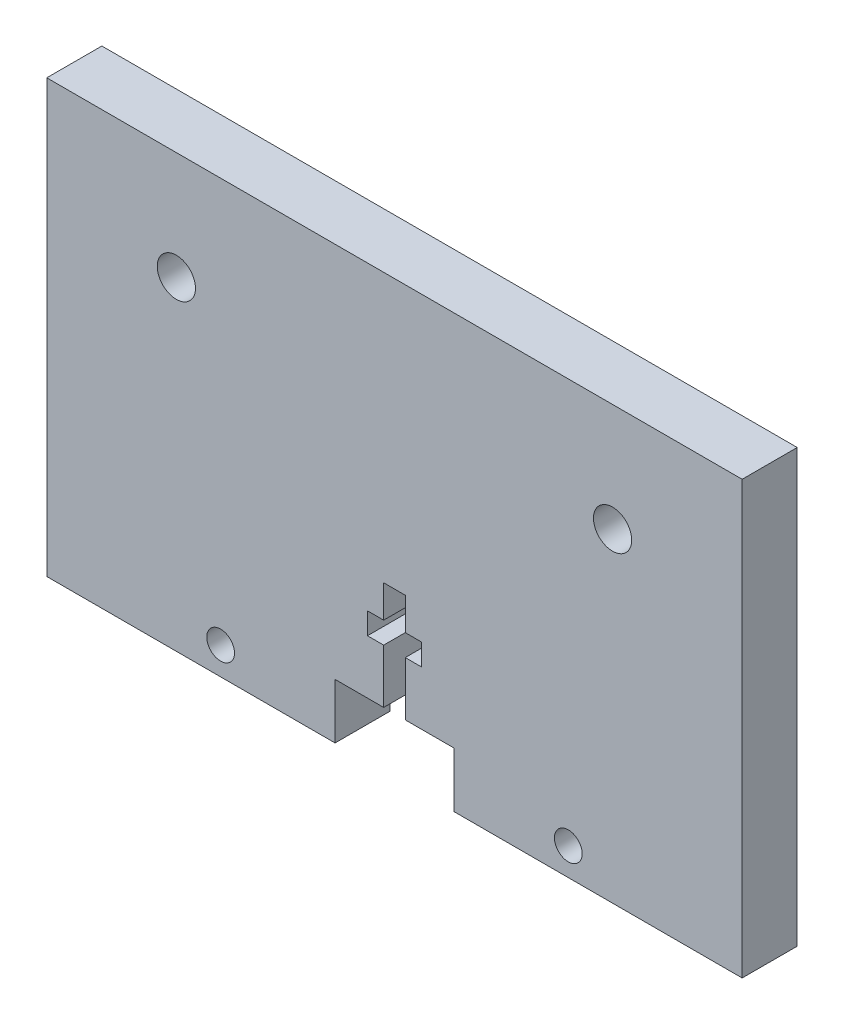
from build123d import *

# Parameters (mm, degrees)
SKETCH1_R           = 1.63195
SKETCH1_R_2         = 2.2479
BOSS_EXTRUDE1_DEPTH = 6.477


with BuildPart() as part:
    # Sketch1 → Boss-Extrude1 (new body)
    with BuildSketch(Plane.XY):
        Polygon((-6.985, -18.923), (-1.27, -18.923), (-1.27, -12.573), (-3.175, -12.573), (-3.175, -10.033), (-1.27, -10.033), (-1.27, -6.223), (1.27, -6.223), (1.27, -10.033), (3.175, -10.033), (3.175, -12.573), (1.27, -12.573), (1.27, -18.923), (6.985, -18.923), (6.985, -25.4), (40.894, -25.4), (40.894, 25.4), (-40.894, 25.4), (-40.894, -25.4), (-6.985, -25.4), align=None)
        with Locations((-20.447, -22.1615)):
            Circle(SKETCH1_R, mode=Mode.SUBTRACT)
        with Locations((20.447, -22.1615)):
            Circle(SKETCH1_R, mode=Mode.SUBTRACT)
        with Locations((-25.654, 12.7)):
            Circle(SKETCH1_R_2, mode=Mode.SUBTRACT)
        with Locations((25.654, 12.7)):
            Circle(SKETCH1_R_2, mode=Mode.SUBTRACT)
    extrude(amount=BOSS_EXTRUDE1_DEPTH)


solid = part.part
